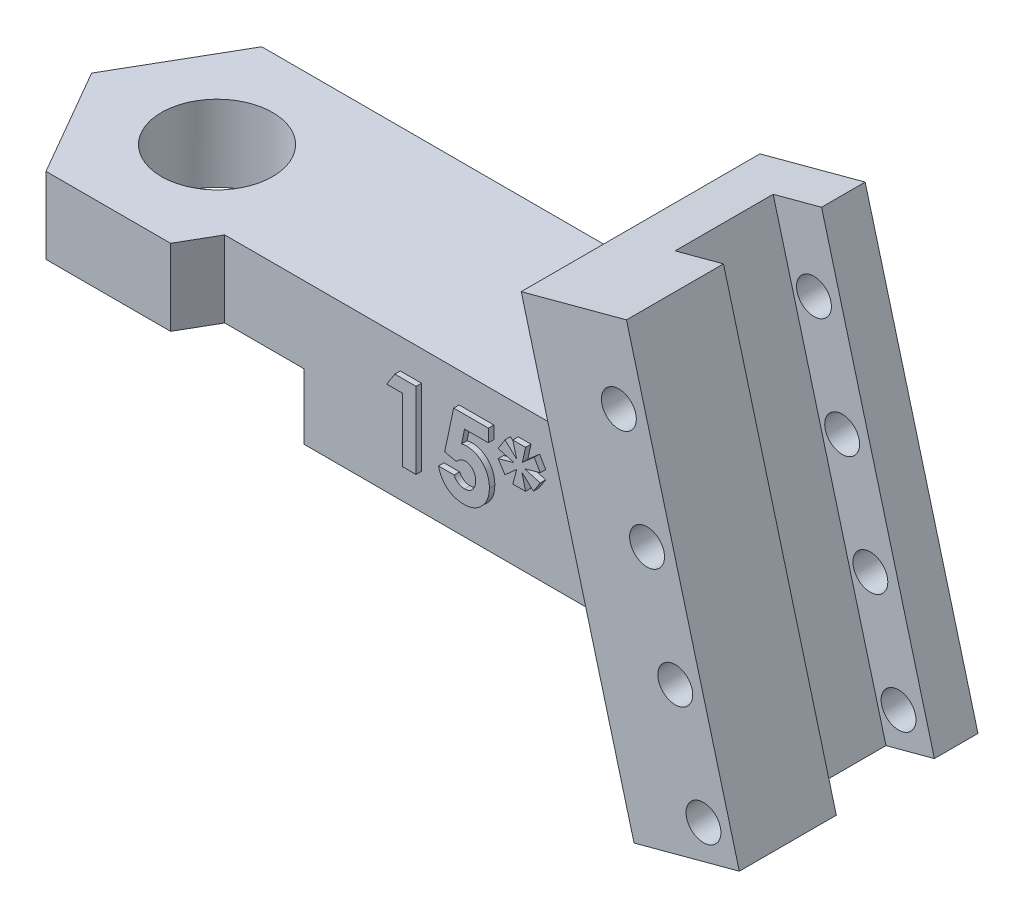
from build123d import *

# Parameters (mm, degrees)
SKETCH1_W                = 25
SKETCH1_H                = 6.75
BOSS_EXTRUDE1_DEPTH      = 6.5
BOSS_EXTRUDE4_DEPTH      = 6.5
BOSS_EXTRUDE3_DEPTH      = 6
BOSS_EXTRUDE3_DEPTH_BACK = 4.95
SKETCH4_W                = 2.3
SKETCH4_H                = 4.5
CUT_EXTRUDE1_DEPTH       = 23
SKETCH6_R                = 2.55
CUT_EXTRUDE2_DEPTH       = 10
BOSS_EXTRUDE5_DEPTH      = 1.575
CUT_EXTRUDE3_DEPTH       = 3
SKETCH9_R                = 0.8
CUT_EXTRUDE4_DEPTH       = 10.95
BOSS_EXTRUDE6_DEPTH      = 0.25


with BuildPart() as part:
    # Sketch1 → Boss-Extrude1 (new body)
    with BuildSketch(Plane(origin=(0, 0, 0), x_dir=(1, 0, 0), z_dir=(0, 1, 0))):
        with Locations((12.5, -3.375)):
            Rectangle(SKETCH1_W, SKETCH1_H)
    extrude(amount=BOSS_EXTRUDE1_DEPTH)

    # Sketch5 → Boss-Extrude4 (add)
    with BuildSketch(Plane(origin=(0, 6.5, 0), x_dir=(1, 0, 0), z_dir=(0, 1, 0))):
        Polygon((-5.715767665, -3.375), (-2.857883832, -8.325), (2.857883832, -8.325), (5.715767665, -3.375), (2.857883832, 1.575), (-2.857883832, 1.575), align=None)
    extrude(amount=-BOSS_EXTRUDE4_DEPTH)

    # Sketch3 → Boss-Extrude3 (add, two sides)
    with BuildSketch(Plane.XY.offset(3.375)) as boss_extrude3_sk:
        Polygon((19.993989967, 13.671468913), (24.823619098, 14.965564139), (30, -4.352952387), (25.170370869, -5.647047613), align=None)
    extrude(amount=BOSS_EXTRUDE3_DEPTH)
    extrude(boss_extrude3_sk.sketch, amount=-BOSS_EXTRUDE3_DEPTH_BACK)

    # Sketch4 → Cut-Extrude1 (cut)
    with BuildSketch(Plane(origin=(-2.078523862, 7.757156658, 0), x_dir=(0.965925826, 0.258819045, 0), z_dir=(-0.258819045, 0.965925826, 0))):
        with Locations((26.701147808, -2.675)):
            Rectangle(SKETCH4_W, SKETCH4_H)
    extrude(amount=-CUT_EXTRUDE1_DEPTH, mode=Mode.SUBTRACT)

    # Sketch6 → Cut-Extrude2 (cut)
    with BuildSketch(Plane(origin=(0, 6.5, 0), x_dir=(1, 0, 0), z_dir=(0, 1, 0))):
        with Locations((0, -3.335615973)):
            Circle(SKETCH6_R)
    extrude(amount=-CUT_EXTRUDE2_DEPTH, mode=Mode.SUBTRACT)

    # Sketch7 → Boss-Extrude5 (add)
    with BuildSketch(Plane(origin=(0, 0, -1.575), x_dir=(-1, 0, 0), z_dir=(0, 0, -1))):
        Polygon((-2.857883832, 0), (-23.657249021, 0), (-25.170370869, -5.647047613), (-30, -4.352952387), (-24.823619098, 14.965564139), (-19.993989967, 13.671468913), (-21.91557927, 6.5), (-2.857883832, 6.5), align=None)
    extrude(amount=-BOSS_EXTRUDE5_DEPTH)

    # Sketch8 → Cut-Extrude3 (cut)
    with BuildSketch(Plane(origin=(0, 0, 0), x_dir=(-1, 0, 0), z_dir=(0, -1, 0))):
        Polygon((-4.67653718, -11.475), (4.67653718, -11.475), (9.353074361, -3.375), (4.67653718, 4.725), (-4.67653718, 4.725), (-9.353074361, -3.375), align=None)
    extrude(amount=-CUT_EXTRUDE3_DEPTH, mode=Mode.SUBTRACT)

    # Sketch9 → Cut-Extrude4 (cut)
    with BuildSketch(Plane(origin=(0, 0, -1.575), x_dir=(-1, 0, 0), z_dir=(0, 0, -1))):
        with Locations((-28.356067858, -3.240528406)):
            Circle(SKETCH9_R)
        with Locations((-27.061972633, 1.589100725)):
            Circle(SKETCH9_R)
        with Locations((-25.767877407, 6.418729856)):
            Circle(SKETCH9_R)
        with Locations((-24.473782182, 11.248358988)):
            Circle(SKETCH9_R)
    extrude(amount=-CUT_EXTRUDE4_DEPTH, mode=Mode.SUBTRACT)

    # Sketch10 → Boss-Extrude6 (add)
    with BuildSketch(Plane.XY.offset(6.75)):
        Polygon((11.821517388, 5.121255448), (12.792571074, 5.121255448), (12.792571074, 1.621255448), (12.164365946, 1.621255448), (12.164365946, 4.537922115), (11.446417228, 4.537922115), align=None)
        with BuildLine():
            Line((14.519434055, 5.121255448), (16.113083895, 5.121255448))
            Line((16.113083895, 5.121255448), (16.113083895, 4.537922115))
            Line((16.113083895, 4.537922115), (15.017230529, 4.537922115))
            Line((15.017230529, 4.537922115), (14.880511779, 3.876063141))
            add(Edge.make_bspline(
                [(14.880511779, 3.876063141), (14.899141666, 3.881251799), (14.93588363, 3.8914849), (14.991235445, 3.901747406), (15.044879068, 3.908399236), (15.080079686, 3.909286501), (15.097158414, 3.909716987)],
                knots=[0, 0, 0, 0, 5.799e-05, 0.000114368, 0.000168722, 0.000219947, 0.000219947, 0.000219947, 0.000219947], degree=3))
            add(Edge.make_bspline(
                [(15.097158414, 3.909716987), (15.134374752, 3.908864196), (15.207736352, 3.907183157), (15.315055064, 3.891224618), (15.41781907, 3.866090403), (15.515713902, 3.830243826), (15.608643929, 3.78358858), (15.696721801, 3.727148811), (15.780055618, 3.66082539), (15.857165021, 3.584576793), (15.928016362, 3.500854107), (15.989617562, 3.410299164), (16.042228831, 3.314203188), (16.084074015, 3.211968849), (16.117101802, 3.104238248), (16.140968418, 2.990942348), (16.15508194, 2.871946875), (16.156985062, 2.790764772), (16.157955689, 2.749360416)],
                knots=[0, 0, 0, 0, 0.000111586, 0.000219961, 0.00032471, 0.000428519, 0.000531991, 0.000636043, 0.000741817, 0.000850891, 0.00096086, 0.001070345, 0.001178899, 0.001288921, 0.00140114, 0.00151651, 0.001635827, 0.001760022, 0.001760022, 0.001760022, 0.001760022], degree=3))
            add(Edge.make_bspline(
                [(16.157955689, 2.749360416), (16.156769568, 2.707486025), (16.154429003, 2.62485561), (16.139158961, 2.503359672), (16.112207063, 2.386993992), (16.075185934, 2.275447061), (16.026412967, 2.169538723), (15.967756798, 2.068171845), (15.898225712, 1.972098843), (15.818502044, 1.882304581), (15.73183196, 1.800230902), (15.639548779, 1.728030529), (15.54230082, 1.6672745), (15.440085734, 1.618173357), (15.333489963, 1.579325407), (15.222481155, 1.551045953), (15.106519819, 1.534829258), (15.027797139, 1.53262981), (14.987783414, 1.531511859)],
                knots=[0, 0, 0, 0, 0.000125626, 0.000247897, 0.00036661, 0.000483454, 0.000599853, 0.000715778, 0.000834286, 0.000954987, 0.001075509, 0.001191914, 0.001305919, 0.001418808, 0.001531482, 0.001645754, 0.001761863, 0.001881886, 0.001881886, 0.001881886, 0.001881886], degree=3))
            add(Edge.make_bspline(
                [(14.987783414, 1.531511859), (14.95200033, 1.532426412), (14.881428601, 1.534230104), (14.777479542, 1.545316541), (14.677261106, 1.564917466), (14.581305344, 1.593285081), (14.488602639, 1.628199138), (14.400224662, 1.671865764), (14.315685761, 1.723453489), (14.235225994, 1.782020834), (14.160152719, 1.847994677), (14.091633788, 1.920214415), (14.029254379, 1.997769753), (13.974349314, 2.08161749), (13.927090704, 2.171633744), (13.885180804, 2.266757653), (13.850877131, 2.367982614), (13.833469005, 2.438157381), (13.824622356, 2.473819551)],
                knots=[0, 0, 0, 0, 0.000107354, 0.000211725, 0.000313201, 0.000413265, 0.000511575, 0.000610032, 0.000708511, 0.000808359, 0.000908217, 0.001007897, 0.001106663, 0.001206422, 0.001308044, 0.00141134, 0.001517986, 0.001628185, 0.001628185, 0.001628185, 0.001628185], degree=3))
            Line((13.824622356, 2.473819551), (14.542571074, 2.473819551))
            add(Edge.make_bspline(
                [(14.542571074, 2.473819551), (14.555695194, 2.44910712), (14.581200423, 2.401081329), (14.629717008, 2.337319877), (14.684028245, 2.282946849), (14.743644216, 2.23743101), (14.808951196, 2.203331319), (14.87728805, 2.17747169), (14.949513264, 2.162528368), (14.998701823, 2.160660305), (15.023540625, 2.159716987)],
                knots=[0, 0, 0, 0, 8.3833e-05, 0.00016292, 0.000239268, 0.000313868, 0.00038695, 0.000459491, 0.000532506, 0.000606986, 0.000606986, 0.000606986, 0.000606986], degree=3))
            add(Edge.make_bspline(
                [(15.023540625, 2.159716987), (15.040852937, 2.160368356), (15.074915202, 2.161649936), (15.125100563, 2.168429817), (15.173004696, 2.181270757), (15.218983754, 2.199052474), (15.263161251, 2.221228283), (15.304903887, 2.249223798), (15.344937907, 2.281447673), (15.382653832, 2.318424679), (15.416813589, 2.35964544), (15.44676796, 2.403939957), (15.473551298, 2.450323998), (15.493390125, 2.500634949), (15.509636448, 2.553370509), (15.521600897, 2.608928478), (15.528751005, 2.667373743), (15.529412913, 2.707272687), (15.529750561, 2.727625641)],
                knots=[0, 0, 0, 0, 5.1959e-05, 0.00010223, 0.000151548, 0.000200376, 0.000249918, 0.000299504, 0.000350859, 0.000403908, 0.00045768, 0.000511159, 0.000564208, 0.00061798, 0.000672982, 0.000729638, 0.000788252, 0.000849286, 0.000849286, 0.000849286, 0.000849286], degree=3))
            add(Edge.make_bspline(
                [(15.529750561, 2.727625641), (15.529358682, 2.747506156), (15.528595879, 2.786204063), (15.52228582, 2.843026451), (15.510997246, 2.896940614), (15.495616468, 2.948359494), (15.475927235, 2.996970851), (15.451865677, 3.043064042), (15.423328999, 3.086406084), (15.390163995, 3.126114575), (15.354797176, 3.162536333), (15.316801847, 3.194390511), (15.276520328, 3.220827268), (15.235204316, 3.243907326), (15.191204624, 3.260704489), (15.14551063, 3.272272075), (15.098170386, 3.280759905), (15.065880633, 3.281258596), (15.049482132, 3.281511859)],
                knots=[0, 0, 0, 0, 5.9632e-05, 0.000116076, 0.000171216, 0.000224671, 0.00027688, 0.000328311, 0.000380426, 0.000432223, 0.00048329, 0.000532573, 0.000580604, 0.000627663, 0.000674276, 0.000721381, 0.000768985, 0.000818109, 0.000818109, 0.000818109, 0.000818109], degree=3))
            add(Edge.make_bspline(
                [(15.049482132, 3.281511859), (15.031669548, 3.28083597), (14.995969309, 3.279481344), (14.942927689, 3.268459116), (14.890525603, 3.250621017), (14.838471643, 3.226010532), (14.787282533, 3.193803172), (14.735607368, 3.156027632), (14.685175827, 3.10993916), (14.65311005, 3.075612361), (14.636521395, 3.057854006)],
                knots=[0, 0, 0, 0, 5.34e-05, 0.000107026, 0.00016179, 0.000219183, 0.000279308, 0.000342972, 0.00041098, 0.000483874, 0.000483874, 0.000483874, 0.000483874], degree=3))
            Line((14.636521395, 3.057854006), (14.107875561, 3.179148077))
            Line((14.107875561, 3.179148077), (14.519434055, 5.121255448))
        make_face()
        Polygon((17.234878766, 5.210999038), (17.8182121, 5.210999038), (17.672378766, 4.537922115), (18.215748157, 5.013983814), (18.491289023, 4.537922115), (17.773340305, 4.335999038), (18.491289023, 4.134075961), (18.180692068, 3.647497435), (17.6541496, 4.134075961), (17.8182121, 3.460999038), (17.234878766, 3.460999038), (17.412262581, 4.134075961), (16.873801042, 3.647497435), (16.561801843, 4.134075961), (17.279750561, 4.335999038), (16.561801843, 4.537922115), (16.873801042, 5.036419711), (17.412262581, 4.537922115), align=None)
    extrude(amount=BOSS_EXTRUDE6_DEPTH)


solid = part.part
